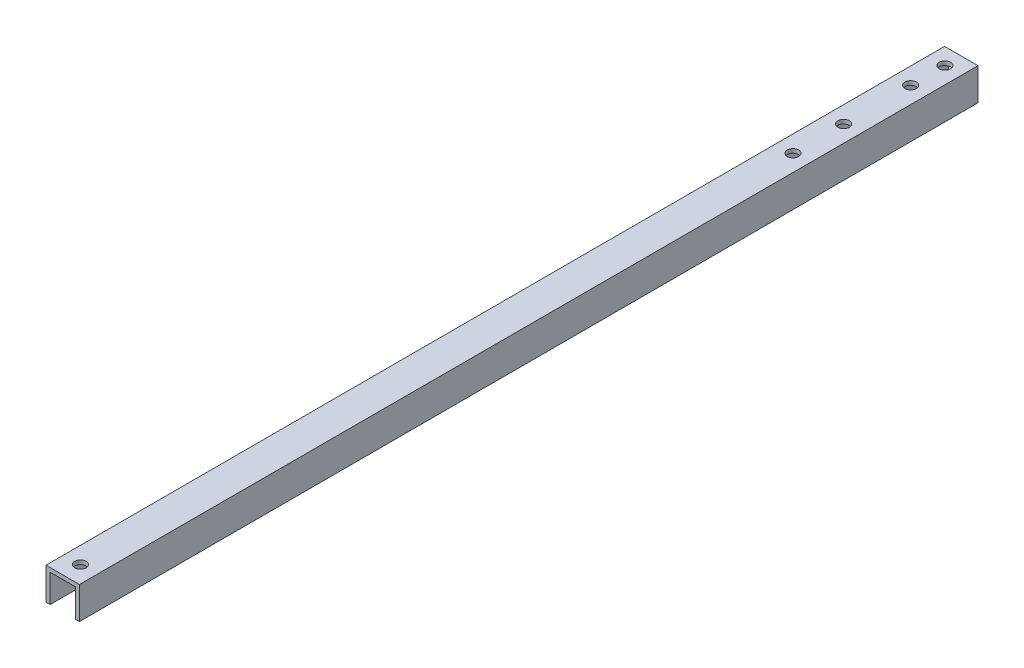
from build123d import *

# Parameters (mm, degrees)
BOSS_EXTRUDE1_DEPTH  = 355
M4_CLEARANCE_HOLE2_D = 4.5


with BuildPart() as part:
    # Sketch1 → Boss-Extrude1 (new body)
    with BuildSketch(Plane.XY):
        Polygon((-6.604, 0), (6.604, 0), (6.604, -12.7), (5.0165, -12.7), (5.0165, -1.5875), (-5.0165, -1.5875), (-5.0165, -12.7), (-6.604, -12.7), align=None)
    extrude(amount=-BOSS_EXTRUDE1_DEPTH)

    # M4 Clearance Hole2 (through all)
    with Locations(Plane(origin=(0, 0, 0), x_dir=(1, 0, 0), z_dir=(0, 1, 0))):
        with Locations((0, 288.5), (0, 7), (0, 348.5), (0, 308.5), (0, 335)):
            Hole(M4_CLEARANCE_HOLE2_D / 2)


solid = part.part
